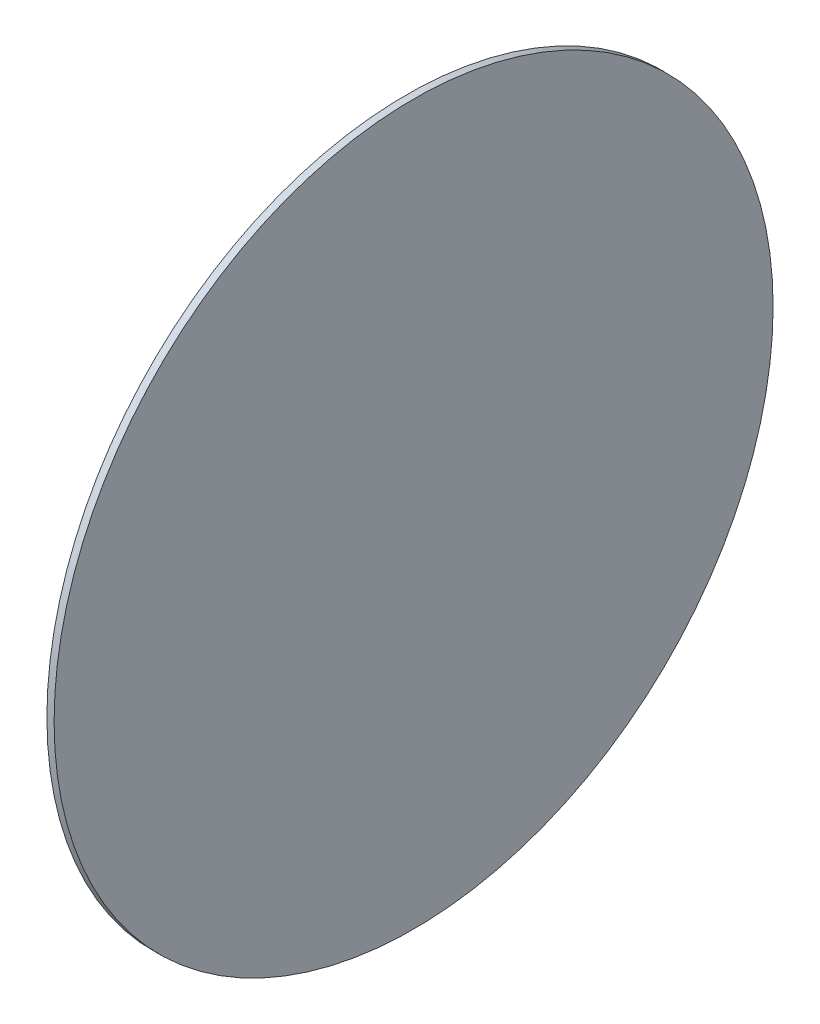
from build123d import *

# Parameters (mm, degrees)
SKETCH2_R           = 150
BOSS_EXTRUDE1_DEPTH = 3


with BuildPart() as part:
    # Sketch2 → Boss-Extrude1 (new body)
    with BuildSketch(Plane(origin=(0, 0, 0), x_dir=(0, 0, -1), z_dir=(1, 0, 0))):
        Circle(SKETCH2_R)
    extrude(amount=BOSS_EXTRUDE1_DEPTH)


solid = part.part
